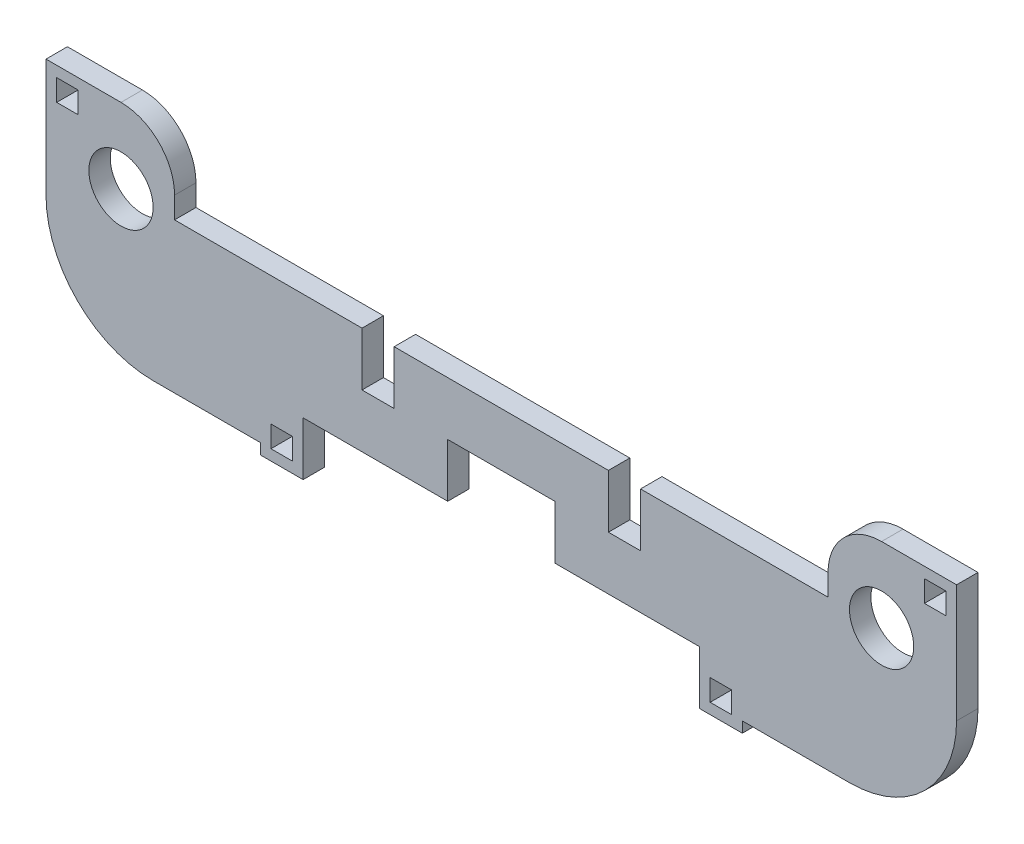
from build123d import *

# Parameters (mm, degrees)
SKETCH1_W           = 2
SKETCH1_H           = 2
SKETCH1_W_2         = 7
SKETCH1_H_2         = 5
BOSS_EXTRUDE2_DEPTH = 2
FILLET1_R           = 10
FILLET2_R           = 10
FILLET3_R           = 5
FILLET4_R           = 5


with BuildPart() as part:
    # Sketch1 → Boss-Extrude2 (new body)
    with BuildSketch(Plane.XY):
        with BuildLine():
            Line((-42.5, 0), (-35.5, 0))
            Line((-35.5, 0), (-35.5, 2))
            ThreePointArc((-35.5, 2), (-37.621320344, 7.121320344), (-32.5, 5))
            Line((-32.5, 5), (-30.5, 5))
            Line((-30.5, 5), (-30.5, 12))
            Line((-30.5, 12), (-42.5, 12))
            Line((-42.5, 12), (-42.5, 0))
        make_face()
        with Locations((-40.5, 10)):
            Rectangle(SKETCH1_W, SKETCH1_H, mode=Mode.SUBTRACT)
        Polygon((-18.5, -5), (-35.5, -5), (-42.5, -5), (-42.5, -9), (-22.5, -9), (-22.5, -10), (-18.5, -10), (-18.5, -9), align=None)
        with Locations((-20.5, -8)):
            Rectangle(SKETCH1_W, SKETCH1_H, mode=Mode.SUBTRACT)
        with Locations((-39, -2.5)):
            Rectangle(SKETCH1_W_2, SKETCH1_H_2)
        with BuildLine():
            Line((-35.5, 0), (-35.5, -5))
            Line((-35.5, -5), (-18.5, -5))
            Line((-18.5, -5), (-5, -5))
            Line((-5, -5), (-5, 0))
            Line((-5, 0), (-10, 0))
            Line((-10, 0), (-13, 0))
            Line((-13, 0), (-13, 5))
            Line((-13, 5), (-30.5, 5))
            Line((-30.5, 5), (-32.5, 5))
            ThreePointArc((-32.5, 5), (-33.378679656, 2.878679656), (-35.5, 2))
            Line((-35.5, 2), (-35.5, 0))
        make_face()
        Polygon((-10, 0), (-5, 0), (5, 0), (10, 0), (10, 5), (-10, 5), align=None)
        Polygon((35.5, -5), (18.5, -5), (18.5, -9), (18.5, -10), (22.5, -10), (22.5, -9), (42.5, -9), (42.5, -5), align=None)
        with Locations((20.5, -8)):
            Rectangle(SKETCH1_W, SKETCH1_H, mode=Mode.SUBTRACT)
        with Locations((39, -2.5)):
            Rectangle(SKETCH1_W_2, SKETCH1_H_2)
        with BuildLine():
            Line((35.5, 2), (35.5, 0))
            Line((35.5, 0), (42.5, 0))
            Line((42.5, 0), (42.5, 12))
            Line((42.5, 12), (30.5, 12))
            Line((30.5, 12), (30.5, 5))
            Line((30.5, 5), (32.5, 5))
            ThreePointArc((32.5, 5), (35.5, 8), (38.5, 5))
            ThreePointArc((38.5, 5), (37.621320344, 2.878679656), (35.5, 2))
        make_face()
        with Locations((40.5, 10)):
            Rectangle(SKETCH1_W, SKETCH1_H, mode=Mode.SUBTRACT)
        with BuildLine():
            Line((5, 0), (5, -5))
            Line((5, -5), (18.5, -5))
            Line((18.5, -5), (35.5, -5))
            Line((35.5, -5), (35.5, 0))
            Line((35.5, 0), (35.5, 2))
            ThreePointArc((35.5, 2), (33.378679656, 2.878679656), (32.5, 5))
            Line((32.5, 5), (30.5, 5))
            Line((30.5, 5), (13, 5))
            Line((13, 5), (13, 0))
            Line((13, 0), (10, 0))
            Line((10, 0), (5, 0))
        make_face()
    extrude(amount=BOSS_EXTRUDE2_DEPTH)

    # Fillet1
    fillet1_edges = [part.edges().sort_by_distance(p)[0] for p in [
        (-42.5, -9, 1),
    ]]
    fillet(fillet1_edges, radius=FILLET1_R)

    # Fillet2
    fillet2_edges = [part.edges().sort_by_distance(p)[0] for p in [
        (42.5, -9, 1),
    ]]
    fillet(fillet2_edges, radius=FILLET2_R)

    # Fillet3
    fillet3_edges = [part.edges().sort_by_distance(p)[0] for p in [
        (-30.5, 12, 1),
    ]]
    fillet(fillet3_edges, radius=FILLET3_R)

    # Fillet4
    fillet4_edges = [part.edges().sort_by_distance(p)[0] for p in [
        (30.5, 12, 1),
    ]]
    fillet(fillet4_edges, radius=FILLET4_R)


solid = part.part
